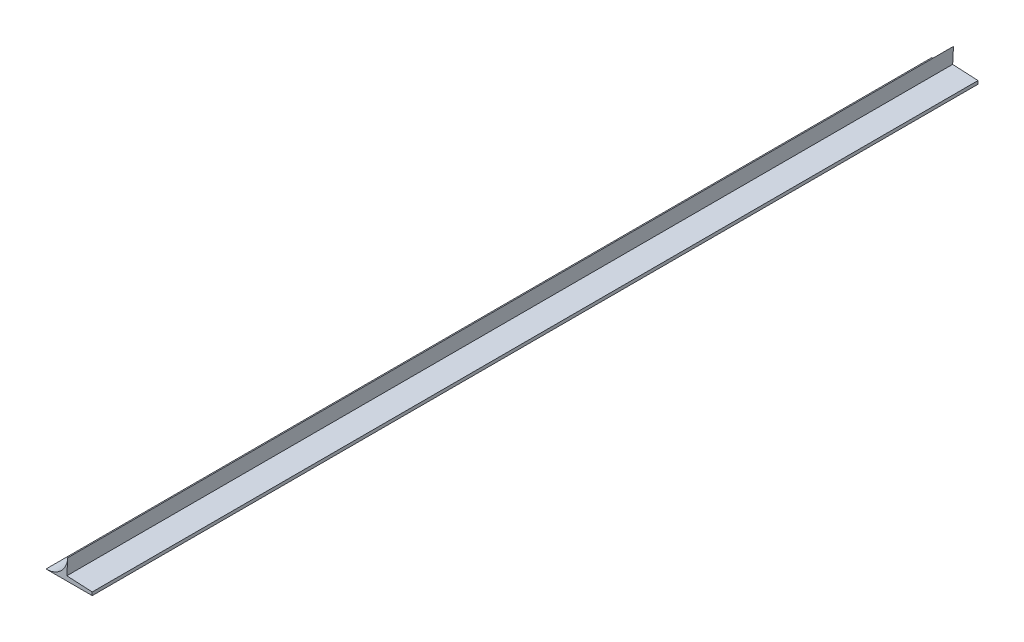
from build123d import *

# Parameters (mm, degrees)
BOSS_EXTRUDE1_DEPTH = 550


with BuildPart() as part:
    # Sketch1 → Boss-Extrude1 (new body)
    with BuildSketch(Plane.XY):
        with BuildLine():
            Line((0, 0), (13.48, 0))
            Line((13.48, 0), (28.694977728, 0))
            Line((28.694977728, 0), (28.694977728, 2))
            Line((28.694977728, 2), (13.48, 2.797383195))
            Line((13.48, 2.797383195), (12.957743561, 2.824753495))
            Line((12.957743561, 2.824753495), (13.48, 12.79))
            ThreePointArc((13.48, 12.79), (9.290689317, 3.706705082), (0, 0))
        make_face()
    extrude(amount=BOSS_EXTRUDE1_DEPTH)


solid = part.part
